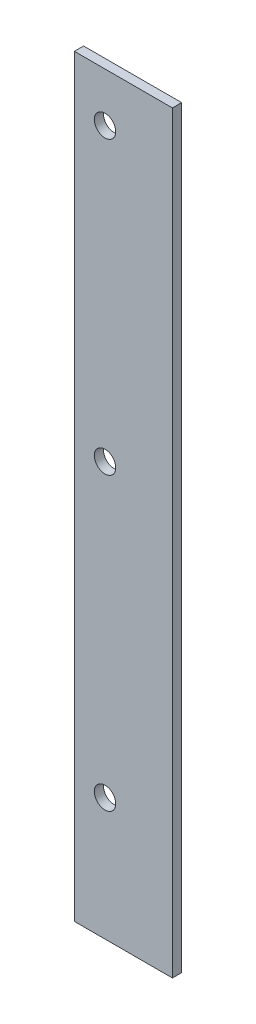
from build123d import *

# Parameters (mm, degrees)
SKETCH1_W           = 16
SKETCH1_H           = 123
BOSS_EXTRUDE1_DEPTH = 1.5
SKETCH2_R           = 1.75
CUT_EXTRUDE1_DEPTH  = 2.5
LPATTERN1_COUNT     = 3
LPATTERN1_PITCH     = 47.5


with BuildPart() as part:
    # Sketch1 → Boss-Extrude1 (new body)
    with BuildSketch(Plane.XY):
        with Locations((8, 61.5)):
            Rectangle(SKETCH1_W, SKETCH1_H)
    extrude(amount=BOSS_EXTRUDE1_DEPTH)

    # Sketch2 → Cut-Extrude1 (cut, through all)
    with BuildSketch(Plane.XY.offset(1.5)):
        with Locations((5, 20)):
            Circle(SKETCH2_R)
    cut_extrude1 = extrude(amount=-CUT_EXTRUDE1_DEPTH, mode=Mode.SUBTRACT)

    # LPattern1: Cut-Extrude1 ×3
    with Locations(*[(0, i * LPATTERN1_PITCH, 0) for i in range(1, LPATTERN1_COUNT)]):
        add(cut_extrude1, mode=Mode.SUBTRACT)


solid = part.part
